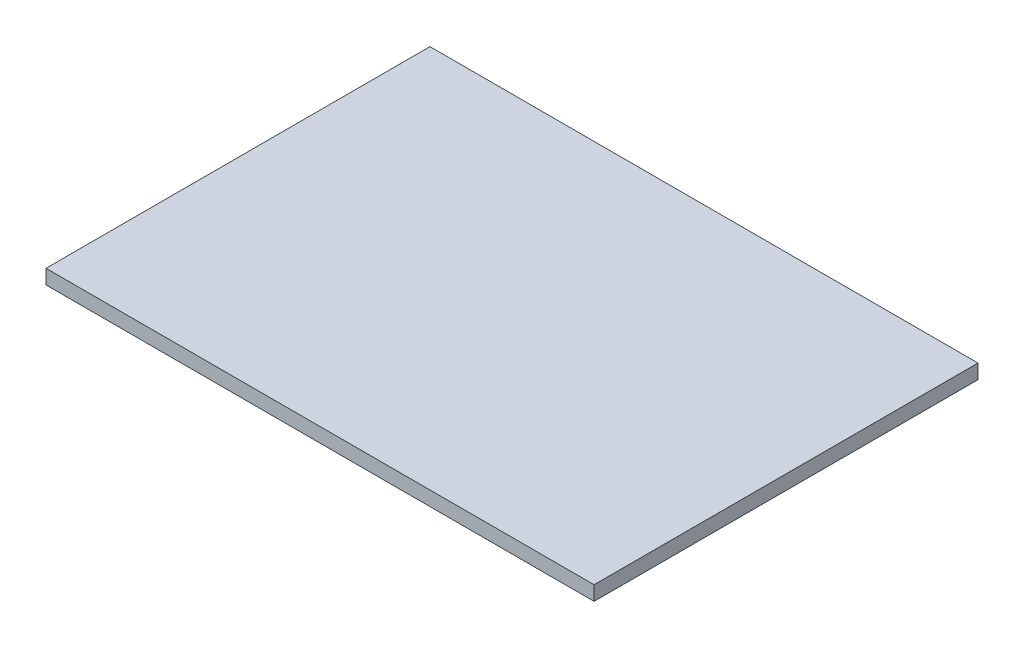
from build123d import *

# Parameters (mm, degrees)
SKETCH_1_W      = 114
SKETCH_1_H      = 79.85863283
EXTRUDE_1_DEPTH = 3


with BuildPart() as part:
    # 草图1 → 凸台-拉伸1 (new body)
    with BuildSketch(Plane(origin=(0, 0, 0), x_dir=(1, 0, 0), z_dir=(0, 1, 0))):
        with Locations((57, -39.929316415)):
            Rectangle(SKETCH_1_W, SKETCH_1_H)
    extrude(amount=EXTRUDE_1_DEPTH)


solid = part.part
